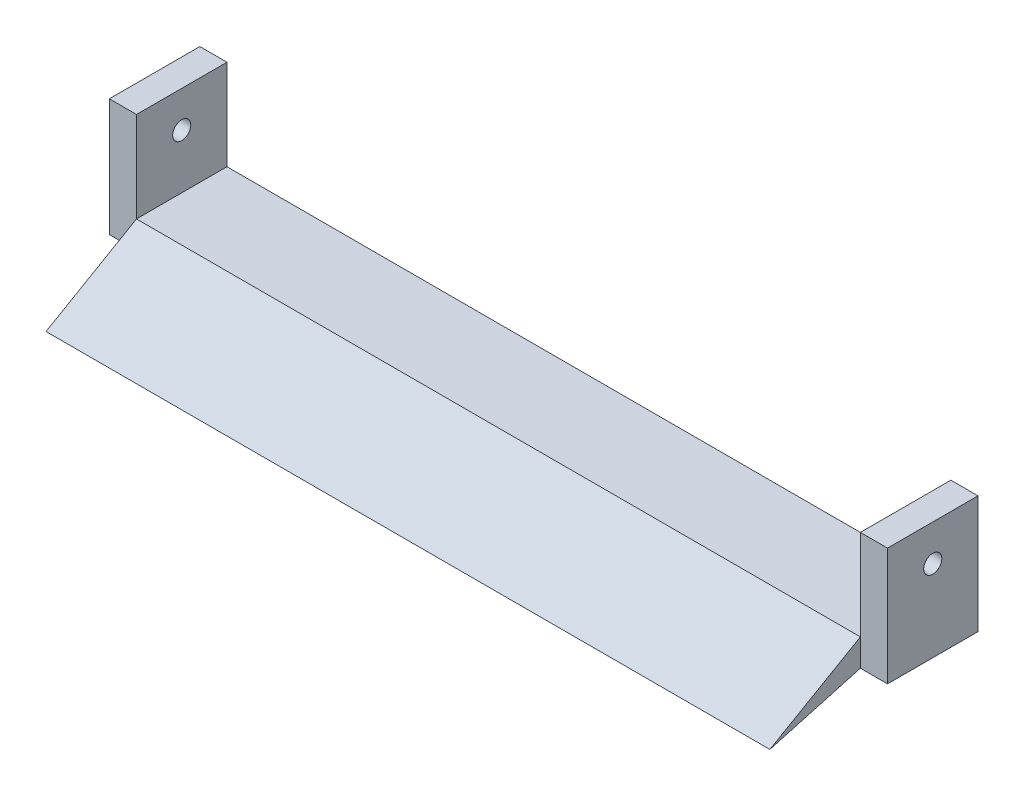
from build123d import *

# Parameters (mm, degrees)
BOSS_EXTRUDE1_DEPTH = 50
SKETCH2_R           = 5
CUT_EXTRUDE1_DEPTH  = 477
BOSS_EXTRUDE2_DEPTH = 200


with BuildPart() as part:
    # Sketch1 → Boss-Extrude1 (new body)
    with BuildSketch(Plane.XY):
        Polygon((200, 32.5), (215, 32.5), (215, -32.5), (-215, -32.5), (-215, 32.5), (-200, 32.5), (-200, -17.5), (200, -17.5), align=None)
    extrude(amount=BOSS_EXTRUDE1_DEPTH)

    # Sketch2 → Cut-Extrude1 (cut)
    with BuildSketch(Plane(origin=(215, 0, 0), x_dir=(0, 0, -1), z_dir=(1, 0, 0))):
        with Locations((-25, 12.5)):
            Circle(SKETCH2_R)
    extrude(amount=-CUT_EXTRUDE1_DEPTH, mode=Mode.SUBTRACT)

    # Sketch3 → Boss-Extrude2 (add, symmetric)
    with BuildSketch(Plane(origin=(0, 0, 0), x_dir=(0, 0, -1), z_dir=(1, 0, 0))):
        Polygon((-50, -32.5), (-100, -46.367513459), (-50, -17.5), align=None)
    extrude(amount=BOSS_EXTRUDE2_DEPTH, both=True)


solid = part.part
